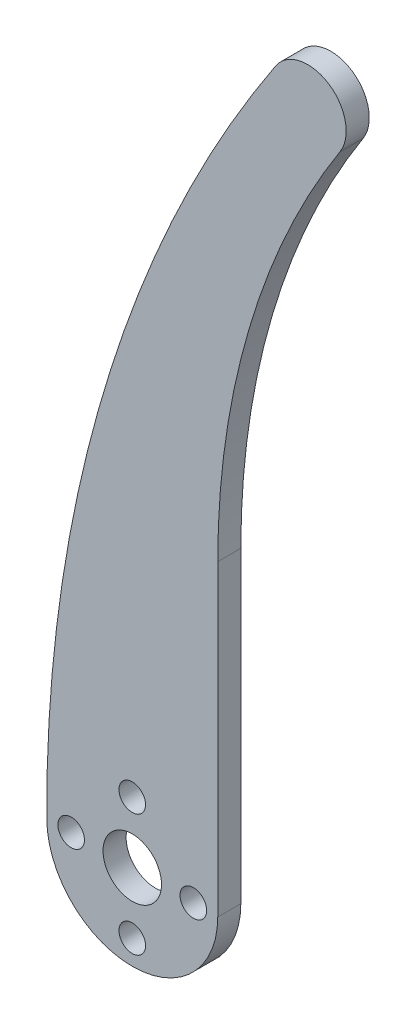
from build123d import *

# Parameters (mm, degrees)
BOSS_EXTRU_3_DEPTH   = 3
D_GAGEMENT_51_D      = 3.4544
D_GAGEMENT_M71_D     = 7.6
D_GAGEMENT_M71_DEPTH = 7.01
D_GAGEMENT_M71_TIP   = 2.283270352


with BuildPart() as part:
    # Esquisse1 → Boss.-Extru.3 (new body)
    with BuildSketch(Plane.XY):
        with BuildLine():
            Line((11.1125, 0), (11.1125, 40))
            ThreePointArc((11.1125, 40), (15.168988239, 68.192952149), (27.009351017, 94.098616722))
            ThreePointArc((27.009351017, 94.098616722), (25.537478416, 100.990911223), (18.635346271, 99.565883395))
            ThreePointArc((18.635346271, 99.565883395), (-3.639418742, 51.966145876), (-11.112370677, -0.053611501))
            ThreePointArc((-11.112370677, -0.053611501), (0.026805829, -11.112467669), (11.1125, 0))
        make_face()
    extrude(amount=BOSS_EXTRU_3_DEPTH)

    # Dégagement #51 (through all)
    with Locations(Plane.XY.offset(3)):
        with Locations((-7.9375, 0), (0, 7.9375), (7.9375, 0), (0, -7.9375)):
            Hole(D_GAGEMENT_51_D / 2)

    # Dégagement M71
    with Locations(Plane.XY.offset(3)):
        with Locations((0, 0)):
            Hole(D_GAGEMENT_M71_D / 2, depth=D_GAGEMENT_M71_DEPTH)
            with Locations((0, 0, -(D_GAGEMENT_M71_DEPTH + D_GAGEMENT_M71_TIP / 2))):  # 118° drill point
                Cone(0, D_GAGEMENT_M71_D / 2, D_GAGEMENT_M71_TIP, mode=Mode.SUBTRACT)


solid = part.part
